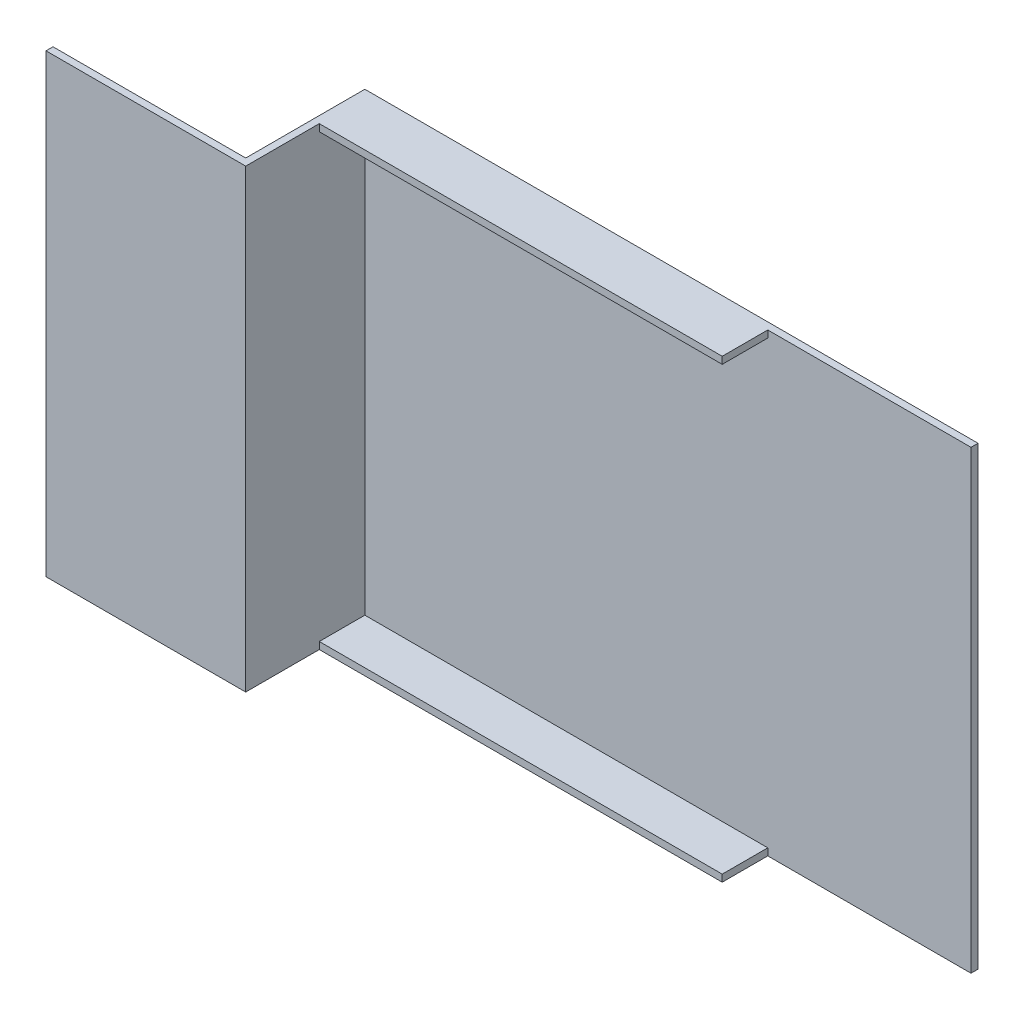
from build123d import *

# Parameters (mm, degrees)
SKETCH1_W           = 175
SKETCH1_H           = 130
BOSS_EXTRUDE1_DEPTH = 2
SKETCH2_W           = 2
SKETCH2_H           = 130
BOSS_EXTRUDE2_DEPTH = 34
SKETCH3_W           = 2
SKETCH3_H           = 130
BOSS_EXTRUDE4_DEPTH = 55
SKETCH5_W           = 115
SKETCH5_H           = 2
BOSS_EXTRUDE5_DEPTH = 13


with BuildPart() as part:
    # Sketch1 → Boss-Extrude1 (new body)
    with BuildSketch(Plane.XY):
        with Locations((87.5, 65)):
            Rectangle(SKETCH1_W, SKETCH1_H)
    extrude(amount=BOSS_EXTRUDE1_DEPTH)

    # Sketch2 → Boss-Extrude2 (add)
    with BuildSketch(Plane.XY.offset(2)):
        with Locations((1, 65)):
            Rectangle(SKETCH2_W, SKETCH2_H)
    extrude(amount=BOSS_EXTRUDE2_DEPTH)

    # Sketch3 → Boss-Extrude4 (add)
    with BuildSketch(Plane.ZY):
        with Locations((35, 65)):
            Rectangle(SKETCH3_W, SKETCH3_H)
    extrude(amount=BOSS_EXTRUDE4_DEPTH)

    # Sketch5 → Boss-Extrude5 (add)
    with BuildSketch(Plane.XY.offset(2)):
        with Locations((59.5, 1)):
            Rectangle(SKETCH5_W, SKETCH5_H)
        with Locations((59.5, 129)):
            Rectangle(SKETCH5_W, SKETCH5_H)
    extrude(amount=BOSS_EXTRUDE5_DEPTH)


solid = part.part
